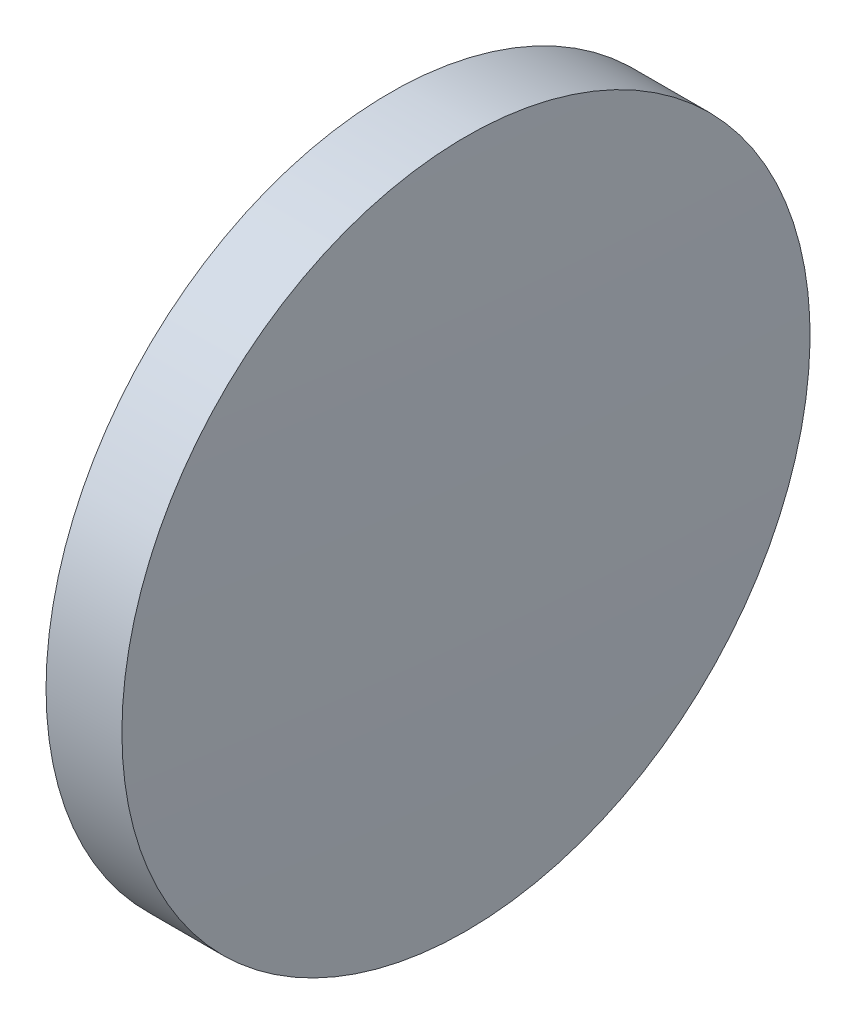
from build123d import *


with BuildPart() as part:
    # 草图1 → 旋转1 (revolve)
    with BuildSketch(Plane.XY, mode=Mode.PRIVATE) as revolve_1_sk:
        with BuildLine():
            Line((115.870046776, 65.233554926), (115.870046776, 77.933554926))
            Line((115.870046776, 77.933554926), (118.670046776, 77.933554926))
            ThreePointArc((118.670046776, 77.933554926), (118.820043676, 71.584342279), (118.870046776, 65.233554926))
            Line((118.870046776, 65.233554926), (115.870046776, 65.233554926))
        make_face()
    revolve(revolve_1_sk.sketch.rotate(Axis((110.165373228, 65.233554926, 0), (1, 0, 0)), 180), axis=Axis((110.165373228, 65.233554926, 0), (1, 0, 0)))  # turned: the seam where the file's is


solid = part.part
